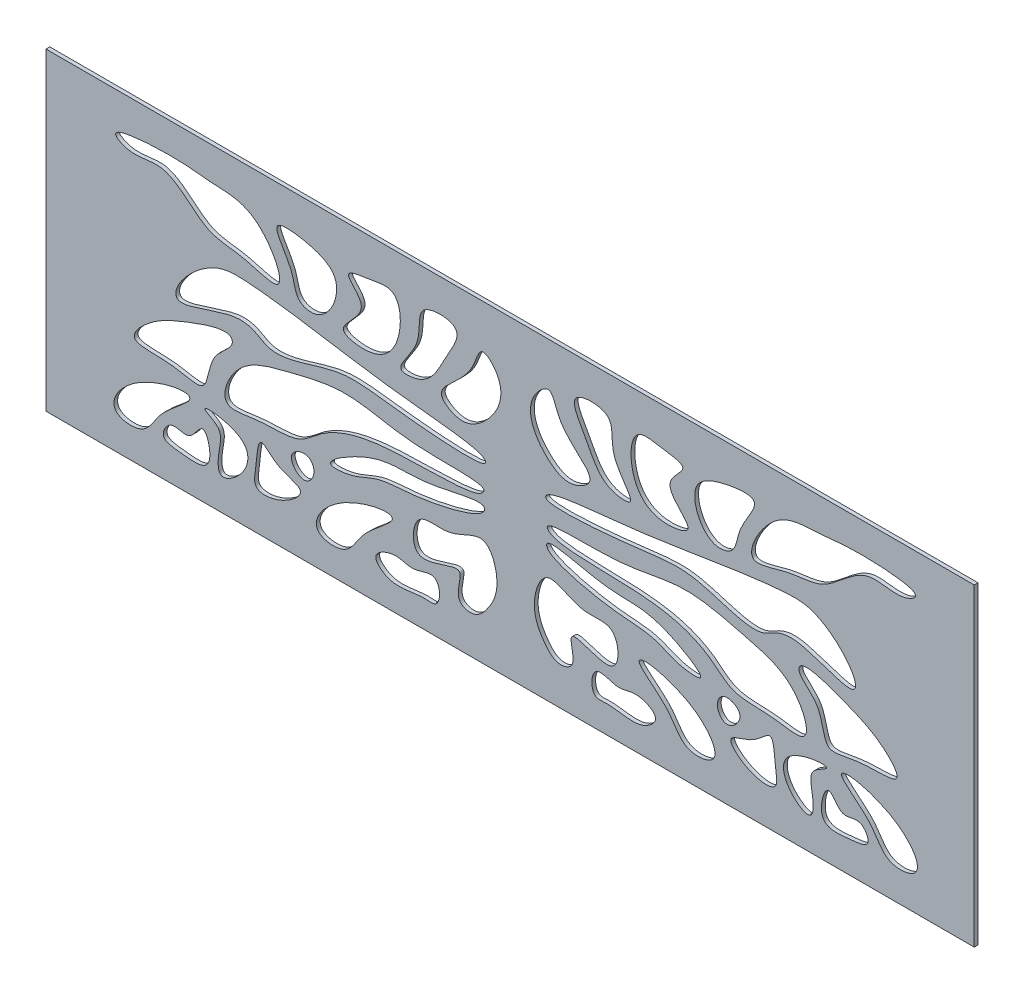
from build123d import *

# Parameters (mm, degrees)
CROQUIS2_W              = 147.96109156
CROQUIS2_H              = 50
SALIENTE_EXTRUIR1_DEPTH = 0.6


with BuildPart() as part:
    # Croquis2 → Saliente-Extruir1 (new body)
    with BuildSketch(Plane.XY):
        with Locations((77.253502781, 153.465234279)):
            Rectangle(CROQUIS2_W, CROQUIS2_H)
        with BuildLine():
            add(Edge.make_bspline(
                [(14.551224489, 133.949300881), (15.339794435, 133.236114201), (19.054527324, 132.867988631), (21.115285544, 137.134926651), (23.712267091, 139.147356551), (28.398960095, 143.187912647), (17.075073655, 141.266126369), (13.23620141, 135.138614458), (14.551224489, 133.949300881)],
                knots=[0, 0, 0, 0, 0.13121694, 0.261967856, 0.433385636, 0.495907082, 0.781181993, 1, 1, 1, 1], degree=3))
        make_face(mode=Mode.SUBTRACT)
        with BuildLine():
            add(Edge.make_bspline(
                [(23.173893283, 136.489705923), (22.448960033, 136.179648207), (21.103114303, 133.80015662), (25.503643026, 133.421133411), (30.493581251, 132.749072798), (28.504626139, 140.548073045), (26.298178477, 135.350306233), (24.07758139, 136.87621802), (23.173893283, 136.489705923)],
                knots=[0, 0, 0, 0, 0.11702101, 0.265473491, 0.499789655, 0.707726475, 0.854123817, 1, 1, 1, 1], degree=3))
        make_face(mode=Mode.SUBTRACT)
        with BuildLine():
            add(Edge.make_bspline(
                [(28.653446204, 141.328848138), (28.930180181, 141.054985237), (31.692970007, 139.93412863), (30.692943929, 136.952293937), (30.578928785, 132.553399456), (35.113008195, 135.198383672), (36.843197585, 141.239253009), (27.93373234, 142.041095069), (28.653446204, 141.328848138)],
                knots=[0, 0, 0, 0, 0.100831532, 0.25515108, 0.381411636, 0.512576107, 0.737763133, 1, 1, 1, 1], degree=3))
        make_face(mode=Mode.SUBTRACT)
        with BuildLine():
            add(Edge.make_bspline(
                [(65.323369879, 136.37313926), (66.207093756, 135.718420823), (66.297580387, 132.505324355), (61.812073032, 133.122258896), (58.578288215, 131.407379997), (54.841674962, 135.047867551), (59.041400191, 137.027543632), (61.775149052, 135.33663376), (64.527913579, 136.962463502), (65.323369879, 136.37313926)],
                knots=[0, 0, 0, 0, 0.160267158, 0.21076581, 0.504986522, 0.580130515, 0.727204348, 0.85574055, 1, 1, 1, 1], degree=3))
        make_face(mode=Mode.SUBTRACT)
        with BuildLine():
            add(Edge.make_bspline(
                [(46.824490156, 133.46440758), (47.613060103, 132.7512209), (51.327792992, 132.38309533), (53.388551211, 136.65003335), (55.985532759, 138.662463251), (60.672225762, 142.703019346), (49.348339323, 140.781233068), (45.509467078, 134.653721158), (46.824490156, 133.46440758)],
                knots=[0, 0, 0, 0, 0.13121694, 0.261967856, 0.433385636, 0.495907082, 0.781181993, 1, 1, 1, 1], degree=3))
        make_face(mode=Mode.SUBTRACT)
        with BuildLine():
            add(Edge.make_bspline(
                [(37.613991334, 141.328848138), (36.980496978, 141.229515845), (36.884560154, 137.841359252), (36.033785237, 133.993457709), (40.952446116, 134.334702535), (45.597100185, 138.349437814), (40.184023662, 138.737667235), (38.127404921, 141.409351694), (37.613991334, 141.328848138)],
                knots=[0, 0, 0, 0, 0.174988013, 0.298355592, 0.478987194, 0.673221019, 0.858181494, 1, 1, 1, 1], degree=3))
        make_face(mode=Mode.SUBTRACT)
        with BuildLine():
            add(Edge.make_bspline(
                [(62.639207318, 143.114584762), (63.653765286, 144.223066583), (67.929172146, 142.76995232), (73.437340552, 147.568661015), (75.835632638, 140.576527063), (74.189691623, 136.798049762), (71.67079006, 134.03226478), (68.033891288, 135.228251373), (71.272696808, 142.070052233), (61.23375644, 135.291686784), (61.643205971, 142.026377461), (62.639207318, 143.114584762)],
                knots=[0, 0, 0, 0, 0.115773361, 0.264232273, 0.386481489, 0.502340138, 0.579489949, 0.628580772, 0.723680545, 0.886344174, 1, 1, 1, 1], degree=3))
        make_face(mode=Mode.SUBTRACT)
        with BuildLine():
            add(Edge.make_bspline(
                [(32.966442667, 152.747280753), (32.838368874, 151.745744832), (28.942863505, 149.715789628), (29.281443, 144.093071767), (26.048490558, 144.281047732), (22.440605159, 145.237257037), (15.326761745, 144.522504537), (19.841272519, 149.420937933), (24.633701653, 151.712615598), (32.751839618, 154.61292413), (32.987826663, 152.914503408), (32.966442667, 152.747280753)],
                knots=[0, 0, 0, 0, 0.100037862, 0.223752743, 0.272835489, 0.361931863, 0.526926229, 0.683101427, 0.832970576, 0.983297058, 1, 1, 1, 1], degree=3))
        make_face(mode=Mode.SUBTRACT)
        with BuildLine():
            add(Edge.make_bspline(
                [(42.409086051, 141.865956311), (42.19227571, 140.831288381), (44.432753689, 138.446945397), (46.483586948, 141.236649058), (45.071422564, 143.930734631), (42.605046043, 142.80112166), (42.409086051, 141.865956311)],
                knots=[0, 0, 0, 0, 0.304007816, 0.526233533, 0.725228194, 1, 1, 1, 1], degree=3))
        make_face(mode=Mode.SUBTRACT)
        with BuildLine():
            add(Edge.make_bspline(
                [(73.072772237, 152.468675869), (72.888434586, 153.466513513), (60.345104498, 152.556084446), (51.862003227, 155.791219802), (41.699394666, 153.14541253), (33.446428669, 151.03536738), (30.319797544, 142.716876285), (38.127500124, 144.555466239), (43.339278906, 143.831030167), (47.650990635, 148.158209866), (56.713158326, 151.652067398), (71.826364324, 150.232025857), (73.10363996, 152.301585881), (73.072772237, 152.468675869)],
                knots=[0, 0, 0, 0, 0.114550047, 0.246019978, 0.351313901, 0.440260507, 0.519920021, 0.570512894, 0.6558102, 0.704961009, 0.808183564, 0.980818356, 1, 1, 1, 1], degree=3))
        make_face(mode=Mode.SUBTRACT)
        with BuildLine():
            add(Edge.make_bspline(
                [(73.15564473, 150.095518152), (72.639032299, 151.019870842), (61.762525681, 147.661875558), (56.939238726, 149.819985179), (46.458333311, 143.342402666), (52.573171328, 143.792375839), (56.173093416, 145.989912217), (62.692503759, 145.85522551), (73.134578957, 148.29446866), (73.224952087, 149.97150944), (73.15564473, 150.095518152)],
                knots=[0, 0, 0, 0, 0.173914473, 0.388452632, 0.503873436, 0.557098589, 0.647485373, 0.766680945, 0.976668095, 1, 1, 1, 1], degree=3))
        make_face(mode=Mode.SUBTRACT)
        with BuildLine():
            add(Edge.make_bspline(
                [(90.952155108, 136.37313926), (90.068431231, 135.718420823), (89.9779446, 132.505324355), (94.463451955, 133.122258896), (97.697236773, 131.407379997), (101.433850025, 135.047867551), (97.234124796, 137.027543632), (94.500375935, 135.33663376), (91.747611408, 136.962463502), (90.952155108, 136.37313926)],
                knots=[0, 0, 0, 0, 0.160267158, 0.21076581, 0.504986522, 0.580130515, 0.727204348, 0.85574055, 1, 1, 1, 1], degree=3))
        make_face(mode=Mode.SUBTRACT)
        with BuildLine():
            add(Edge.make_bspline(
                [(93.636317669, 143.114584762), (92.621759701, 144.223066583), (88.346352841, 142.76995232), (82.838184435, 147.568661015), (80.43989235, 140.576527063), (82.085833364, 136.798049762), (84.604734927, 134.03226478), (88.241633699, 135.228251373), (85.00282818, 142.070052233), (95.041768548, 135.291686784), (94.632319016, 142.026377461), (93.636317669, 143.114584762)],
                knots=[0, 0, 0, 0, 0.115773361, 0.264232273, 0.386481489, 0.502340138, 0.579489949, 0.628580772, 0.723680545, 0.886344174, 1, 1, 1, 1], degree=3))
        make_face(mode=Mode.SUBTRACT)
        with BuildLine():
            add(Edge.make_bspline(
                [(109.451034831, 133.46440758), (108.662464884, 132.7512209), (104.947731995, 132.38309533), (102.886973776, 136.65003335), (100.289992228, 138.662463251), (95.603299225, 142.703019346), (106.927185665, 140.781233068), (110.76605791, 134.653721158), (109.451034831, 133.46440758)],
                knots=[0, 0, 0, 0, 0.13121694, 0.261967856, 0.433385636, 0.495907082, 0.781181993, 1, 1, 1, 1], degree=3))
        make_face(mode=Mode.SUBTRACT)
        with BuildLine():
            add(Edge.make_bspline(
                [(127.622078783, 141.328848138), (127.345344806, 141.054985237), (124.58255498, 139.93412863), (125.582581058, 136.952293937), (125.696596202, 132.553399456), (121.162516792, 135.198383672), (119.432327402, 141.239253009), (128.341792647, 142.041095069), (127.622078783, 141.328848138)],
                knots=[0, 0, 0, 0, 0.100831532, 0.25515108, 0.381411636, 0.512576107, 0.737763133, 1, 1, 1, 1], degree=3))
        make_face(mode=Mode.SUBTRACT)
        with BuildLine():
            add(Edge.make_bspline(
                [(133.101631704, 136.489705923), (133.826564954, 136.179648207), (135.172410684, 133.80015662), (130.771881961, 133.421133411), (125.781943736, 132.749072798), (127.770898849, 140.548073045), (129.97734651, 135.350306233), (132.197943597, 136.87621802), (133.101631704, 136.489705923)],
                knots=[0, 0, 0, 0, 0.11702101, 0.265473491, 0.499789655, 0.707726475, 0.854123817, 1, 1, 1, 1], degree=3))
        make_face(mode=Mode.SUBTRACT)
        with BuildLine():
            add(Edge.make_bspline(
                [(118.661533653, 141.328848138), (119.295028009, 141.229515845), (119.390964833, 137.841359252), (120.24173975, 133.993457709), (115.323078871, 134.334702535), (110.678424802, 138.349437814), (116.091501325, 138.737667235), (118.148120066, 141.409351694), (118.661533653, 141.328848138)],
                knots=[0, 0, 0, 0, 0.174988013, 0.298355592, 0.478987194, 0.673221019, 0.858181494, 1, 1, 1, 1], degree=3))
        make_face(mode=Mode.SUBTRACT)
        with BuildLine():
            add(Edge.make_bspline(
                [(141.724300498, 133.949300881), (140.935730552, 133.236114201), (137.220997663, 132.867988631), (135.160239443, 137.134926651), (132.563257896, 139.147356551), (127.876564892, 143.187912647), (139.200451332, 141.266126369), (143.039323577, 135.138614459), (141.724300498, 133.949300881)],
                knots=[0, 0, 0, 0, 0.13121694, 0.261967856, 0.433385636, 0.495907082, 0.781181993, 1, 1, 1, 1], degree=3))
        make_face(mode=Mode.SUBTRACT)
        with BuildLine():
            add(Edge.make_bspline(
                [(113.866438936, 141.865956311), (114.083249277, 140.831288381), (111.842771299, 138.446945397), (109.791938039, 141.236649058), (111.204102423, 143.930734631), (113.670478944, 142.80112166), (113.866438936, 141.865956311)],
                knots=[0, 0, 0, 0, 0.304007816, 0.526233533, 0.725228194, 1, 1, 1, 1], degree=3))
        make_face(mode=Mode.SUBTRACT)
        with BuildLine():
            add(Edge.make_bspline(
                [(83.119880257, 150.095518152), (83.636492688, 151.019870842), (94.512999306, 147.661875558), (99.336286261, 149.819985179), (109.817191676, 143.342402666), (103.702353659, 143.792375839), (100.102431571, 145.989912217), (93.583021228, 145.85522551), (83.14094603, 148.29446866), (83.0505729, 149.97150944), (83.119880257, 150.095518152)],
                knots=[0, 0, 0, 0, 0.173914473, 0.388452632, 0.503873436, 0.557098589, 0.647485373, 0.766680945, 0.976668095, 1, 1, 1, 1], degree=3))
        make_face(mode=Mode.SUBTRACT)
        with BuildLine():
            add(Edge.make_bspline(
                [(83.20275275, 152.468675869), (83.387090401, 153.466513513), (95.930420489, 152.556084446), (104.413521761, 155.791219802), (114.576130321, 153.14541253), (122.829096318, 151.03536738), (125.955727444, 142.716876285), (118.148024863, 144.555466239), (112.936246081, 143.831030167), (108.624534352, 148.158209866), (99.562366661, 151.652067398), (84.449160663, 150.232025857), (83.171885027, 152.301585881), (83.20275275, 152.468675869)],
                knots=[0, 0, 0, 0, 0.114550047, 0.246019978, 0.351313901, 0.440260507, 0.519920021, 0.570512894, 0.6558102, 0.704961009, 0.808183564, 0.980818356, 1, 1, 1, 1], degree=3))
        make_face(mode=Mode.SUBTRACT)
        with BuildLine():
            add(Edge.make_bspline(
                [(123.30908232, 152.747280753), (123.437156113, 151.745744832), (127.332661482, 149.715789628), (126.994081987, 144.093071767), (130.227034429, 144.281047732), (133.834919828, 145.237257037), (140.948763242, 144.522504537), (136.434252468, 149.420937933), (131.641823334, 151.712615598), (123.523685369, 154.61292413), (123.287698324, 152.914503408), (123.30908232, 152.747280753)],
                knots=[0, 0, 0, 0, 0.100037862, 0.223752743, 0.272835489, 0.361931863, 0.526926229, 0.683101427, 0.832970576, 0.983297058, 1, 1, 1, 1], degree=3))
        make_face(mode=Mode.SUBTRACT)
        with BuildLine():
            add(Edge.make_bspline(
                [(72.91508114, 156.984358061), (71.338428895, 157.924946554), (55.843766007, 158.929942007), (41.204058587, 162.159238167), (28.059916796, 162.661440723), (19.504422472, 151.027977501), (35.330195183, 158.286165496), (38.771089147, 152.897543042), (49.749285684, 158.260279378), (57.893997646, 156.54376925), (74.596482569, 155.234021321), (73.160865462, 156.837729719), (72.91508114, 156.984358061)],
                knots=[0, 0, 0, 0, 0.099677328, 0.267067778, 0.297767809, 0.406677629, 0.47274056, 0.561818037, 0.712100252, 0.844613011, 0.984461301, 1, 1, 1, 1], degree=3))
        make_face(mode=Mode.SUBTRACT)
        with BuildLine():
            add(Edge.make_bspline(
                [(14.657896841, 171.859765475), (14.87445433, 171.685879971), (17.241806327, 170.408292763), (22.903130673, 172.975759893), (28.178148518, 165.51075917), (34.421837051, 165.865133042), (42.83697344, 162.492469179), (37.323142053, 173.200806778), (29.256580091, 173.012581495), (24.164193325, 174.10410552), (13.117772907, 173.09641273), (14.657896841, 171.859765475)],
                knots=[0, 0, 0, 0, 0.018173889, 0.122894497, 0.279653893, 0.384629408, 0.472626168, 0.608786908, 0.726153064, 0.870750066, 1, 1, 1, 1], degree=3))
        make_face(mode=Mode.SUBTRACT)
        with BuildLine():
            add(Edge.make_bspline(
                [(40.16459936, 172.482873033), (39.598625174, 171.626663919), (42.955291079, 167.92854161), (42.906373929, 163.725109626), (47.950731676, 162.534920655), (51.333670162, 170.119069346), (45.595129804, 172.662427767), (40.643750509, 173.207735742), (40.16459936, 172.482873033)],
                knots=[0, 0, 0, 0, 0.195722298, 0.325152471, 0.402012975, 0.648328218, 0.8343024, 1, 1, 1, 1], degree=3))
        make_face(mode=Mode.SUBTRACT)
        with BuildLine():
            add(Edge.make_bspline(
                [(51.500461199, 171.46265181), (51.374924138, 170.784273673), (56.219252411, 167.684340778), (48.354651492, 163.351493244), (55.07253491, 161.800409267), (60.013414051, 164.416579015), (60.1704104, 173.635030746), (55.118619374, 172.452289538), (51.605467684, 172.030086665), (51.500461199, 171.46265181)],
                knots=[0, 0, 0, 0, 0.113933947, 0.288077368, 0.377523831, 0.561215078, 0.781648315, 0.904699033, 1, 1, 1, 1], degree=3))
        make_face(mode=Mode.SUBTRACT)
        with BuildLine():
            add(Edge.make_bspline(
                [(63.638327135, 172.640710939), (62.289379404, 171.655675545), (64.008434152, 167.424856494), (58.177861317, 162.12148719), (64.650900819, 162.407083476), (66.172139882, 166.758691236), (70.469796446, 173.430567268), (64.849484244, 173.525128172), (63.638327135, 172.640710939)],
                knots=[0, 0, 0, 0, 0.18416172, 0.363281009, 0.422910842, 0.690341932, 0.834649801, 1, 1, 1, 1], degree=3))
        make_face(mode=Mode.SUBTRACT)
        with BuildLine():
            add(Edge.make_bspline(
                [(66.486306925, 161.827779416), (65.399800655, 163.542286114), (71.295440797, 166.040251797), (72.320312056, 172.744492466), (77.32191276, 167.87668464), (74.2781782, 162.281600892), (69.686929824, 159.620911832), (66.91428415, 161.152431433), (66.486306925, 161.827779416)],
                knots=[0, 0, 0, 0, 0.267800279, 0.390798431, 0.490723643, 0.760932173, 0.894512878, 1, 1, 1, 1], degree=3))
        make_face(mode=Mode.SUBTRACT)
        with BuildLine():
            add(Edge.make_bspline(
                [(83.360443847, 156.984358061), (84.937096092, 157.924946554), (100.43175898, 158.929942007), (115.0714664, 162.159238167), (128.215608191, 162.661440723), (136.771102515, 151.027977501), (120.945329804, 158.286165496), (117.50443584, 152.897543042), (106.526239303, 158.260279378), (98.381527341, 156.54376925), (81.679042418, 155.234021321), (83.114659525, 156.837729719), (83.360443847, 156.984358061)],
                knots=[0, 0, 0, 0, 0.099677328, 0.267067778, 0.297767809, 0.406677629, 0.47274056, 0.561818037, 0.712100252, 0.844613011, 0.984461301, 1, 1, 1, 1], degree=3))
        make_face(mode=Mode.SUBTRACT)
        with BuildLine():
            add(Edge.make_bspline(
                [(89.789218062, 161.827779416), (90.875724333, 163.542286114), (84.98008419, 166.040251797), (83.955212931, 172.744492466), (78.953612227, 167.87668464), (81.997346787, 162.281600892), (86.588595163, 159.620911832), (89.361240837, 161.152431433), (89.789218062, 161.827779416)],
                knots=[0, 0, 0, 0, 0.267800279, 0.390798431, 0.490723643, 0.760932173, 0.894512878, 1, 1, 1, 1], degree=3))
        make_face(mode=Mode.SUBTRACT)
        with BuildLine():
            add(Edge.make_bspline(
                [(92.637197852, 172.640710939), (93.986145583, 171.655675545), (92.267090836, 167.424856494), (98.09766367, 162.12148719), (91.624624168, 162.407083476), (90.103385105, 166.758691236), (85.805728541, 173.430567268), (91.426040743, 173.525128172), (92.637197852, 172.640710939)],
                knots=[0, 0, 0, 0, 0.18416172, 0.363281009, 0.422910842, 0.690341932, 0.834649801, 1, 1, 1, 1], degree=3))
        make_face(mode=Mode.SUBTRACT)
        with BuildLine():
            add(Edge.make_bspline(
                [(104.775063788, 171.46265181), (104.900600849, 170.784273673), (100.056272577, 167.684340778), (107.920873496, 163.351493244), (101.202990077, 161.800409267), (96.262110936, 164.416579015), (96.105114587, 173.635030746), (101.156905613, 172.452289538), (104.670057303, 172.030086665), (104.775063788, 171.46265181)],
                knots=[0, 0, 0, 0, 0.113933947, 0.288077368, 0.377523831, 0.561215078, 0.781648315, 0.904699033, 1, 1, 1, 1], degree=3))
        make_face(mode=Mode.SUBTRACT)
        with BuildLine():
            add(Edge.make_bspline(
                [(116.110925627, 172.482873033), (116.676899813, 171.626663919), (113.320233908, 167.92854161), (113.369151058, 163.725109626), (108.324793311, 162.534920655), (104.941854825, 170.119069346), (110.680395183, 172.662427767), (115.631774478, 173.207735742), (116.110925627, 172.482873033)],
                knots=[0, 0, 0, 0, 0.195722298, 0.325152471, 0.402012975, 0.648328218, 0.8343024, 1, 1, 1, 1], degree=3))
        make_face(mode=Mode.SUBTRACT)
        with BuildLine():
            add(Edge.make_bspline(
                [(141.617628147, 171.859765475), (141.401070657, 171.685879971), (139.03371866, 170.408292763), (133.372394314, 172.975759893), (128.097376469, 165.51075917), (121.853687936, 165.865133042), (113.438551547, 162.492469179), (118.952382934, 173.200806778), (127.018944896, 173.012581495), (132.111331662, 174.10410552), (143.15775208, 173.09641273), (141.617628147, 171.859765475)],
                knots=[0, 0, 0, 0, 0.018173889, 0.122894497, 0.279653893, 0.384629408, 0.472626168, 0.608786908, 0.726153064, 0.870750066, 1, 1, 1, 1], degree=3))
        make_face(mode=Mode.SUBTRACT)
    extrude(amount=SALIENTE_EXTRUIR1_DEPTH)


solid = part.part
